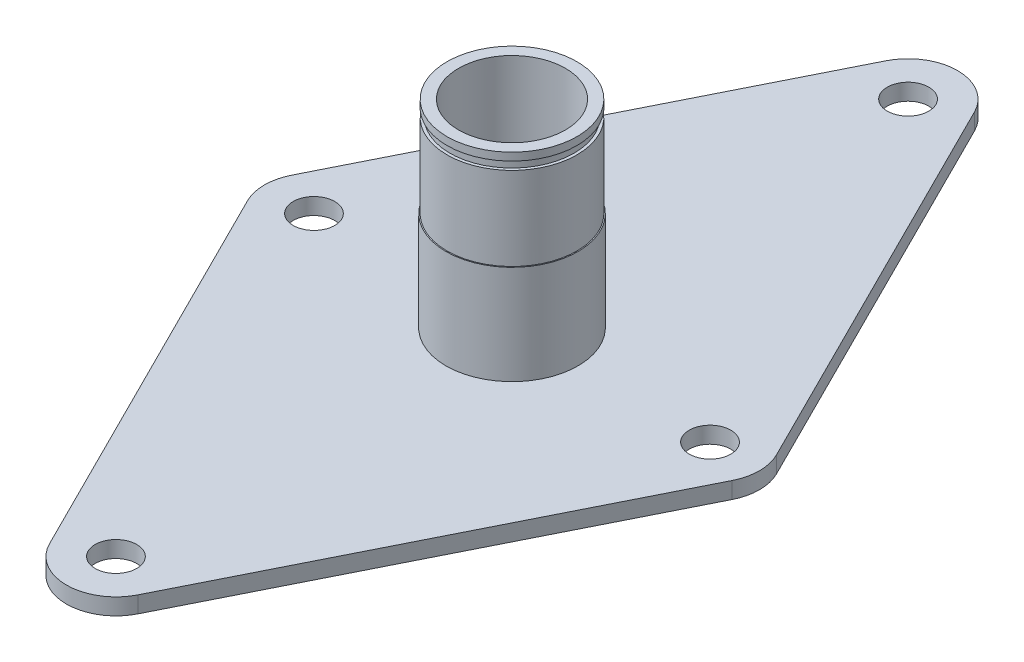
from build123d import *

# Parameters (mm, degrees)
SKETCH1_R           = 4
BOSS_EXTRUDE1_DEPTH = 3.175
SKETCH2_R           = 12.7
SKETCH2_R_2         = 10.287
EXTRUDE_THIN1_DEPTH = 38.1
SKETCH3_R           = 12.7
SKETCH3_R_2         = 12.5
CUT_EXTRUDE2_DEPTH  = 19.05
SKETCH4_R           = 12.5
SKETCH4_R_2         = 11.95
CUT_EXTRUDE3_DEPTH  = 1.55


with BuildPart() as part:
    # Sketch1 → Boss-Extrude1 (new body)
    with BuildSketch(Plane(origin=(0, 0, 0), x_dir=(1, 0, 0), z_dir=(0, 1, 0))):
        with BuildLine():
            Line((-8.519418994, 80.459709497), (-46.619418994, 4.259709497))
            ThreePointArc((-46.619418994, 4.259709497), (-47.625, 0), (-46.619418994, -4.259709497))
            Line((-46.619418994, -4.259709497), (-8.519418994, -80.459709497))
            ThreePointArc((-8.519418994, -80.459709497), (0, -85.725), (8.519418994, -80.459709497))
            Line((8.519418994, -80.459709497), (46.619418994, -4.259709497))
            ThreePointArc((46.619418994, -4.259709497), (47.625, 0), (46.619418994, 4.259709497))
            Line((46.619418994, 4.259709497), (8.519418994, 80.459709497))
            ThreePointArc((8.519418994, 80.459709497), (0, 85.725), (-8.519418994, 80.459709497))
        make_face()
        with Locations((0, 76.2)):
            Circle(SKETCH1_R, mode=Mode.SUBTRACT)
        with Locations((0, -76.2)):
            Circle(SKETCH1_R, mode=Mode.SUBTRACT)
        with Locations((-38.1, 0)):
            Circle(SKETCH1_R, mode=Mode.SUBTRACT)
        with Locations((38.1, 0)):
            Circle(SKETCH1_R, mode=Mode.SUBTRACT)
    extrude(amount=-BOSS_EXTRUDE1_DEPTH)

    # Sketch2 → Extrude-Thin1 (add)
    with BuildSketch(Plane(origin=(0, 0, 0), x_dir=(1, 0, 0), z_dir=(0, 1, 0))):
        Circle(SKETCH2_R)
        Circle(SKETCH2_R_2, mode=Mode.SUBTRACT)
    extrude(amount=EXTRUDE_THIN1_DEPTH)

    # Sketch3 → Cut-Extrude2 (cut)
    with BuildSketch(Plane(origin=(0, 38.1, 0), x_dir=(1, 0, 0), z_dir=(0, 1, 0))):
        Circle(SKETCH3_R)
        Circle(SKETCH3_R_2, mode=Mode.SUBTRACT)
    extrude(amount=-CUT_EXTRUDE2_DEPTH, mode=Mode.SUBTRACT)

    # Sketch4 → Cut-Extrude3 (cut)
    with BuildSketch(Plane(origin=(0, 35.063199876, 0), x_dir=(-1, 0, 0), z_dir=(0, -1, 0))):
        Circle(SKETCH4_R)
        Circle(SKETCH4_R_2, mode=Mode.SUBTRACT)
    extrude(amount=-CUT_EXTRUDE3_DEPTH, mode=Mode.SUBTRACT)


solid = part.part
